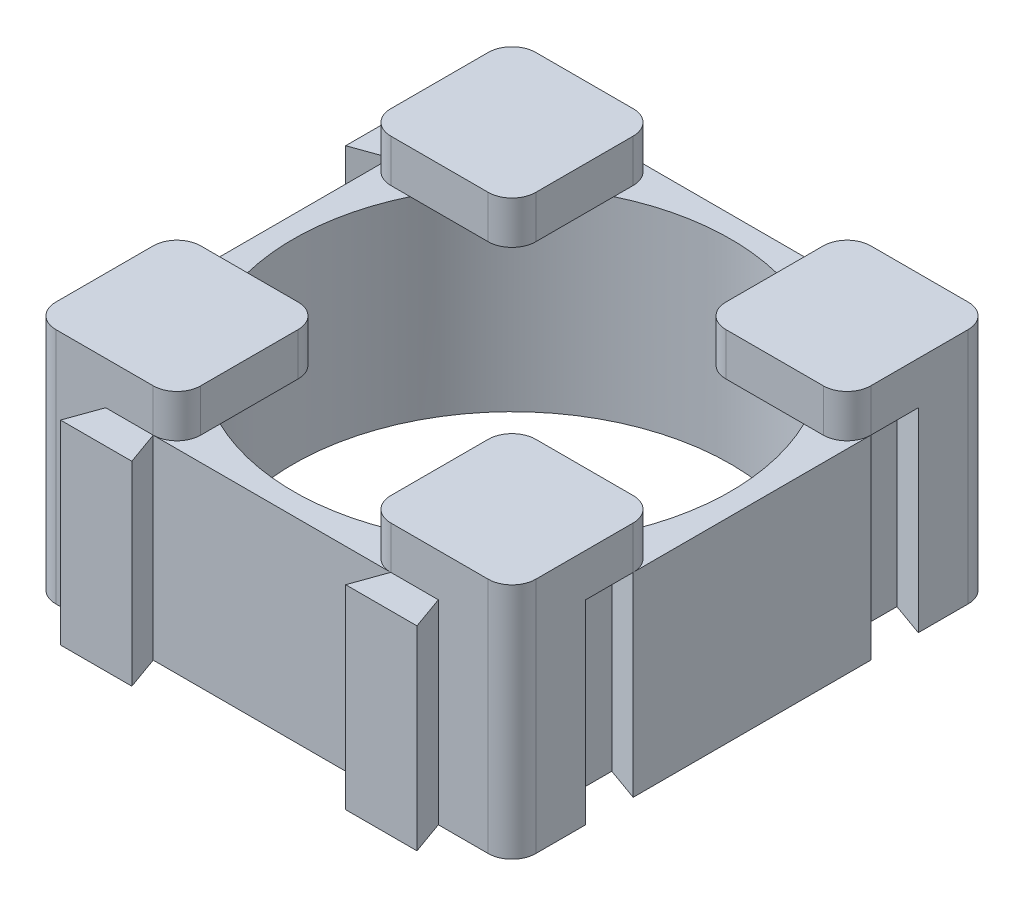
from build123d import *

# Parameters (mm, degrees)
SKETCH1_R           = 9.2
BOSS_EXTRUDE1_DEPTH = 8.2
BOSS_EXTRUDE2_DEPTH = 1.8


with BuildPart() as part:
    # Sketch1 → Boss-Extrude1 (new body)
    with BuildSketch(Plane(origin=(0, 0, 0), x_dir=(1, 0, 0), z_dir=(0, 1, 0))):
        with BuildLine():
            Line((-9.1, 10.1), (-7, 10.1))
            Line((-7, 10.1), (-7.5, 8.7))
            Line((-7.5, 8.7), (-4.5, 8.7))
            Line((-4.5, 8.7), (-5, 10.1))
            Line((-5, 10.1), (5, 10.1))
            Line((5, 10.1), (4.5, 8.7))
            Line((4.5, 8.7), (7.5, 8.7))
            Line((7.5, 8.7), (7, 10.1))
            Line((7, 10.1), (9.1, 10.1))
            ThreePointArc((9.1, 10.1), (9.807106781, 9.807106781), (10.1, 9.1))
            Line((10.1, 9.1), (10.1, 7))
            Line((10.1, 7), (8.7, 7.5))
            Line((8.7, 7.5), (8.7, 4.5))
            Line((8.7, 4.5), (10.1, 5))
            Line((10.1, 5), (10.1, -5))
            Line((10.1, -5), (8.7, -4.5))
            Line((8.7, -4.5), (8.7, -7.5))
            Line((8.7, -7.5), (10.1, -7))
            Line((10.1, -7), (10.1, -9.1))
            ThreePointArc((10.1, -9.1), (9.807106781, -9.807106781), (9.1, -10.1))
            Line((9.1, -10.1), (7, -10.1))
            Line((7, -10.1), (7.5, -11.5))
            Line((7.5, -11.5), (4.5, -11.5))
            Line((4.5, -11.5), (5, -10.1))
            Line((5, -10.1), (-5, -10.1))
            Line((-5, -10.1), (-4.5, -11.5))
            Line((-4.5, -11.5), (-7.5, -11.5))
            Line((-7.5, -11.5), (-7, -10.1))
            Line((-7, -10.1), (-9.1, -10.1))
            ThreePointArc((-9.1, -10.1), (-9.807106781, -9.807106781), (-10.1, -9.1))
            Line((-10.1, -9.1), (-10.1, -7))
            Line((-10.1, -7), (-11.5, -7.5))
            Line((-11.5, -7.5), (-11.5, -4.5))
            Line((-11.5, -4.5), (-10.1, -5))
            Line((-10.1, -5), (-10.1, 5))
            Line((-10.1, 5), (-11.5, 4.5))
            Line((-11.5, 4.5), (-11.5, 7.5))
            Line((-11.5, 7.5), (-10.1, 7))
            Line((-10.1, 7), (-10.1, 9.1))
            ThreePointArc((-10.1, 9.1), (-9.807106781, 9.807106781), (-9.1, 10.1))
        make_face()
        Circle(SKETCH1_R, mode=Mode.SUBTRACT)
    extrude(amount=BOSS_EXTRUDE1_DEPTH)

    # Sketch2 → Boss-Extrude2 (add)
    with BuildSketch(Plane(origin=(0, 8.2, 0), x_dir=(1, 0, 0), z_dir=(0, 1, 0))):
        with BuildLine():
            Line((-9.1, 4), (-5, 4))
            ThreePointArc((-5, 4), (-4.292893219, 4.292893219), (-4, 5))
            Line((-4, 5), (-4, 9.1))
            ThreePointArc((-4, 9.1), (-4.292893219, 9.807106781), (-5, 10.1))
            Line((-5, 10.1), (-9.1, 10.1))
            ThreePointArc((-9.1, 10.1), (-9.807106781, 9.807106781), (-10.1, 9.1))
            Line((-10.1, 9.1), (-10.1, 5))
            ThreePointArc((-10.1, 5), (-9.807106781, 4.292893219), (-9.1, 4))
        make_face()
        with BuildLine():
            Line((10.1, 9.1), (10.1, 5))
            ThreePointArc((10.1, 5), (9.807106781, 4.292893219), (9.1, 4))
            Line((9.1, 4), (5, 4))
            ThreePointArc((5, 4), (4.292893219, 4.292893219), (4, 5))
            Line((4, 5), (4, 9.1))
            ThreePointArc((4, 9.1), (4.292893219, 9.807106781), (5, 10.1))
            Line((5, 10.1), (9.1, 10.1))
            ThreePointArc((9.1, 10.1), (9.807106781, 9.807106781), (10.1, 9.1))
        make_face()
        with BuildLine():
            Line((9.1, -4), (5, -4))
            ThreePointArc((5, -4), (4.292893219, -4.292893219), (4, -5))
            Line((4, -5), (4, -9.1))
            ThreePointArc((4, -9.1), (4.292893219, -9.807106781), (5, -10.1))
            Line((5, -10.1), (9.1, -10.1))
            ThreePointArc((9.1, -10.1), (9.807106781, -9.807106781), (10.1, -9.1))
            Line((10.1, -9.1), (10.1, -5))
            ThreePointArc((10.1, -5), (9.807106781, -4.292893219), (9.1, -4))
        make_face()
        with BuildLine():
            Line((-4, -5), (-4, -9.1))
            ThreePointArc((-4, -9.1), (-4.292893219, -9.807106781), (-5, -10.1))
            Line((-5, -10.1), (-9.1, -10.1))
            ThreePointArc((-9.1, -10.1), (-9.807106781, -9.807106781), (-10.1, -9.1))
            Line((-10.1, -9.1), (-10.1, -5))
            ThreePointArc((-10.1, -5), (-9.807106781, -4.292893219), (-9.1, -4))
            Line((-9.1, -4), (-5, -4))
            ThreePointArc((-5, -4), (-4.292893219, -4.292893219), (-4, -5))
        make_face()
    extrude(amount=BOSS_EXTRUDE2_DEPTH)


solid = part.part
